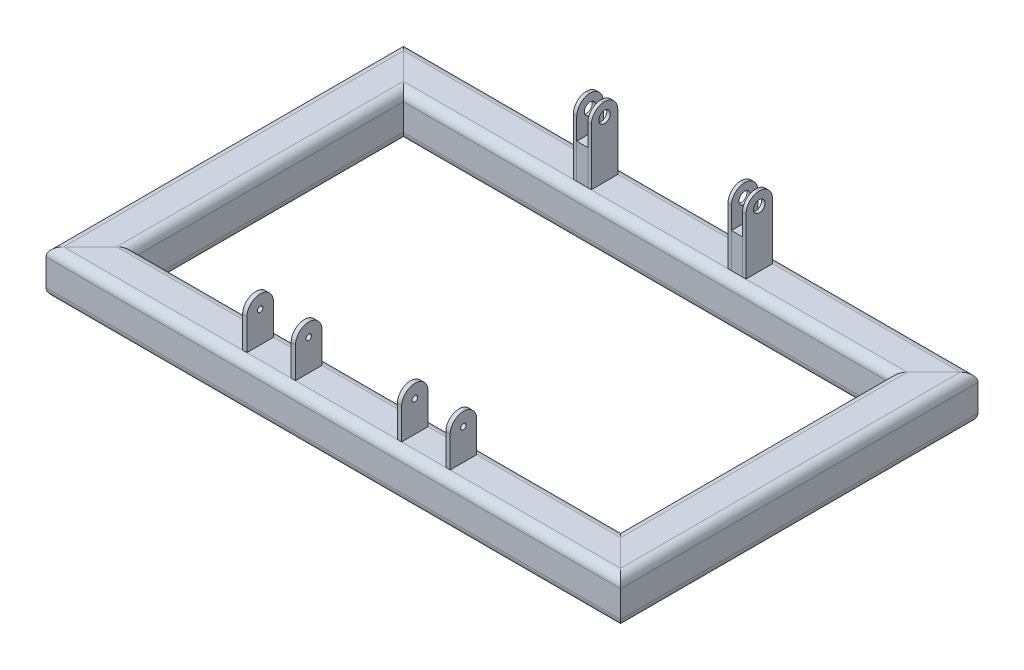
from build123d import *

# Parameters (mm, degrees)
TUBE_SQUARE_TS25X25X2_5_1_DEPTH      = 323.760512242
TUBE_SQUARE_TS25X25X2_5_1_DEPTH_BACK = 18.960512242
TUBE_SQUARE_TS25X25X2_5_1_2_DEPTH    = 217.921024484
TUBE_SQUARE_TS25X25X2_5_1_3_DEPTH    = 342.721024484
TUBE_SQUARE_TS25X25X2_5_1_4_DEPTH    = 217.921024484
SKETCH124_W                          = 2.5
SKETCH124_H                          = 15.24
BOSS_EXTRUDE1_DEPTH                  = 25.4
BOSS_EXTRUDE1_2_DEPTH                = 25.4
SKETCH124_W_2                        = 2.502031313
BOSS_EXTRUDE1_3_DEPTH                = 25.4
BOSS_EXTRUDE1_4_DEPTH                = 25.4
SKETCH125_R                          = 1.5875
CUT_EXTRUDE1_DEPTH                   = 297.651541074
SKETCH126_W                          = 2
SKETCH126_H                          = 15.24
BOSS_EXTRUDE2_DEPTH                  = 40
BOSS_EXTRUDE2_2_DEPTH                = 40
BOSS_EXTRUDE2_3_DEPTH                = 40
BOSS_EXTRUDE2_4_DEPTH                = 40
SKETCH129_R                          = 3.295
CUT_EXTRUDE7_DEPTH                   = 296.090946455
SKETCH130_W                          = 6.35
SKETCH130_H                          = 15.24
BOSS_EXTRUDE3_DEPTH                  = 20
SKETCH130_W_2                        = 6.36
BOSS_EXTRUDE3_2_DEPTH                = 20


with BuildPart() as part:
    # Sketch123 → Tube square TS25X25X2.5(1) (new, two sides)
    with BuildSketch(Plane.ZY.offset(-304.8)) as tube_square_ts25x25x2_5_1_sk:
        with BuildLine():
            Line((-7.62, -12.7), (7.62, -12.7))
            ThreePointArc((7.62, -12.7), (11.212102448, -11.212102448), (12.7, -7.62))
            Line((12.7, -7.62), (12.7, 7.62))
            ThreePointArc((12.7, 7.62), (11.212102448, 11.212102448), (7.62, 12.7))
            Line((7.62, 12.7), (-7.62, 12.7))
            ThreePointArc((-7.62, 12.7), (-11.212102448, 11.212102448), (-12.7, 7.62))
            Line((-12.7, 7.62), (-12.7, -7.62))
            ThreePointArc((-12.7, -7.62), (-11.212102448, -11.212102448), (-7.62, -12.7))
        make_face()
        with BuildLine():
            Line((-7.62, -10.16), (7.62, -10.16))
            ThreePointArc((7.62, -10.16), (9.416051224, -9.416051224), (10.16, -7.62))
            Line((10.16, -7.62), (10.16, 7.62))
            ThreePointArc((10.16, 7.62), (9.416051224, 9.416051224), (7.62, 10.16))
            Line((7.62, 10.16), (-7.62, 10.16))
            ThreePointArc((-7.62, 10.16), (-9.416051224, 9.416051224), (-10.16, 7.62))
            Line((-10.16, 7.62), (-10.16, -7.62))
            ThreePointArc((-10.16, -7.62), (-9.416051224, -9.416051224), (-7.62, -10.16))
        make_face(mode=Mode.SUBTRACT)
    extrude(amount=TUBE_SQUARE_TS25X25X2_5_1_DEPTH)
    extrude(tube_square_ts25x25x2_5_1_sk.sketch, amount=-TUBE_SQUARE_TS25X25X2_5_1_DEPTH_BACK)

    # Tube square TS25X25X2.5(1) mitre 1
    split(bisect_by=Plane(origin=(304.8, 0, 0), x_dir=(0, -1, 0), z_dir=(-0.707106781, 0, 0.707106781)), keep=Keep.TOP)

    # Tube square TS25X25X2.5(1) mitre 2
    split(bisect_by=Plane(origin=(0, 0, 0), x_dir=(0, 1, 0), z_dir=(0.707106781, 0, 0.707106781)), keep=Keep.TOP)


with BuildPart() as body_2:
    # Sketch123 on segment 2 (carried to segment 2) → Tube square TS25X25X2.5_1 2 (new body)
    with BuildSketch(Plane(origin=(0, 0, 18.960512242), x_dir=(-1, 0, 0), z_dir=(0, 0, -1))):
        with BuildLine():
            Line((-7.62, -12.7), (7.62, -12.7))
            ThreePointArc((7.62, -12.7), (11.212102448, -11.212102448), (12.7, -7.62))
            Line((12.7, -7.62), (12.7, 7.62))
            ThreePointArc((12.7, 7.62), (11.212102448, 11.212102448), (7.62, 12.7))
            Line((7.62, 12.7), (-7.62, 12.7))
            ThreePointArc((-7.62, 12.7), (-11.212102448, 11.212102448), (-12.7, 7.62))
            Line((-12.7, 7.62), (-12.7, -7.62))
            ThreePointArc((-12.7, -7.62), (-11.212102448, -11.212102448), (-7.62, -12.7))
        make_face()
        with BuildLine():
            Line((-7.62, -10.16), (7.62, -10.16))
            ThreePointArc((7.62, -10.16), (9.416051224, -9.416051224), (10.16, -7.62))
            Line((10.16, -7.62), (10.16, 7.62))
            ThreePointArc((10.16, 7.62), (9.416051224, 9.416051224), (7.62, 10.16))
            Line((7.62, 10.16), (-7.62, 10.16))
            ThreePointArc((-7.62, 10.16), (-9.416051224, 9.416051224), (-10.16, 7.62))
            Line((-10.16, 7.62), (-10.16, -7.62))
            ThreePointArc((-10.16, -7.62), (-9.416051224, -9.416051224), (-7.62, -10.16))
        make_face(mode=Mode.SUBTRACT)
    extrude(amount=TUBE_SQUARE_TS25X25X2_5_1_2_DEPTH)

    # Tube square TS25X25X2.5_1 2 mitre 1
    split(bisect_by=Plane(origin=(0, 0, 0), x_dir=(0, -1, 0), z_dir=(-0.707106781, 0, -0.707106781)), keep=Keep.TOP)

    # Tube square TS25X25X2.5_1 2 mitre 2
    split(bisect_by=Plane(origin=(0, 0, -180), x_dir=(0, -1, 0), z_dir=(-0.707106781, 0, 0.707106781)), keep=Keep.TOP)


with BuildPart() as body_3:
    # Sketch123 on segment 3 (carried to segment 3) → Tube square TS25X25X2.5_1 3 (new body)
    with BuildSketch(Plane(origin=(-18.960512242, 0, -180), x_dir=(0, 0, -1), z_dir=(1, 0, 0))):
        with BuildLine():
            Line((-7.62, -12.7), (7.62, -12.7))
            ThreePointArc((7.62, -12.7), (11.212102448, -11.212102448), (12.7, -7.62))
            Line((12.7, -7.62), (12.7, 7.62))
            ThreePointArc((12.7, 7.62), (11.212102448, 11.212102448), (7.62, 12.7))
            Line((7.62, 12.7), (-7.62, 12.7))
            ThreePointArc((-7.62, 12.7), (-11.212102448, 11.212102448), (-12.7, 7.62))
            Line((-12.7, 7.62), (-12.7, -7.62))
            ThreePointArc((-12.7, -7.62), (-11.212102448, -11.212102448), (-7.62, -12.7))
        make_face()
        with BuildLine():
            Line((-7.62, -10.16), (7.62, -10.16))
            ThreePointArc((7.62, -10.16), (9.416051224, -9.416051224), (10.16, -7.62))
            Line((10.16, -7.62), (10.16, 7.62))
            ThreePointArc((10.16, 7.62), (9.416051224, 9.416051224), (7.62, 10.16))
            Line((7.62, 10.16), (-7.62, 10.16))
            ThreePointArc((-7.62, 10.16), (-9.416051224, 9.416051224), (-10.16, 7.62))
            Line((-10.16, 7.62), (-10.16, -7.62))
            ThreePointArc((-10.16, -7.62), (-9.416051224, -9.416051224), (-7.62, -10.16))
        make_face(mode=Mode.SUBTRACT)
    extrude(amount=TUBE_SQUARE_TS25X25X2_5_1_3_DEPTH)

    # Tube square TS25X25X2.5_1 3 mitre 1
    split(bisect_by=Plane(origin=(0, 0, -180), x_dir=(0, 1, 0), z_dir=(0.707106781, 0, -0.707106781)), keep=Keep.TOP)

    # Tube square TS25X25X2.5_1 3 mitre 2
    split(bisect_by=Plane(origin=(304.8, 0, -180), x_dir=(0, -1, 0), z_dir=(-0.707106781, 0, -0.707106781)), keep=Keep.TOP)


with BuildPart() as body_4:
    # Sketch123 on segment 4 (carried to segment 4) → Tube square TS25X25X2.5_1 4 (new body)
    with BuildSketch(Plane(origin=(304.8, 0, -198.960512242), x_dir=(1, 0, 0), z_dir=(0, 0, 1))):
        with BuildLine():
            Line((-7.62, -12.7), (7.62, -12.7))
            ThreePointArc((7.62, -12.7), (11.212102448, -11.212102448), (12.7, -7.62))
            Line((12.7, -7.62), (12.7, 7.62))
            ThreePointArc((12.7, 7.62), (11.212102448, 11.212102448), (7.62, 12.7))
            Line((7.62, 12.7), (-7.62, 12.7))
            ThreePointArc((-7.62, 12.7), (-11.212102448, 11.212102448), (-12.7, 7.62))
            Line((-12.7, 7.62), (-12.7, -7.62))
            ThreePointArc((-12.7, -7.62), (-11.212102448, -11.212102448), (-7.62, -12.7))
        make_face()
        with BuildLine():
            Line((-7.62, -10.16), (7.62, -10.16))
            ThreePointArc((7.62, -10.16), (9.416051224, -9.416051224), (10.16, -7.62))
            Line((10.16, -7.62), (10.16, 7.62))
            ThreePointArc((10.16, 7.62), (9.416051224, 9.416051224), (7.62, 10.16))
            Line((7.62, 10.16), (-7.62, 10.16))
            ThreePointArc((-7.62, 10.16), (-9.416051224, 9.416051224), (-10.16, 7.62))
            Line((-10.16, 7.62), (-10.16, -7.62))
            ThreePointArc((-10.16, -7.62), (-9.416051224, -9.416051224), (-7.62, -10.16))
        make_face(mode=Mode.SUBTRACT)
    extrude(amount=TUBE_SQUARE_TS25X25X2_5_1_4_DEPTH)

    # Tube square TS25X25X2.5_1 4 mitre 1
    split(bisect_by=Plane(origin=(304.8, 0, -180), x_dir=(0, 1, 0), z_dir=(0.707106781, 0, 0.707106781)), keep=Keep.TOP)

    # Tube square TS25X25X2.5_1 4 mitre 2
    split(bisect_by=Plane(origin=(304.8, 0, 0), x_dir=(0, 1, 0), z_dir=(0.707106781, 0, -0.707106781)), keep=Keep.TOP)


with BuildPart() as body_5:
    # Sketch124 → Boss-Extrude1 (new body)
    with BuildSketch(Plane(origin=(0, 12.7, 0), x_dir=(1, 0, 0), z_dir=(0, 1, 0))):
        with Locations((185.352150923, 0)):
            Rectangle(SKETCH124_W, SKETCH124_H)
    extrude(amount=BOSS_EXTRUDE1_DEPTH)


with BuildPart() as body_6:
    # Sketch124 → Boss-Extrude1 2 (new body)
    with BuildSketch(Plane(origin=(0, 12.7, 0), x_dir=(1, 0, 0), z_dir=(0, 1, 0))):
        with Locations((124.352150923, 0)):
            Rectangle(SKETCH124_W, SKETCH124_H)
    extrude(amount=BOSS_EXTRUDE1_2_DEPTH)


with BuildPart() as body_7:
    # Sketch124 → Boss-Extrude1 3 (new body)
    with BuildSketch(Plane(origin=(0, 12.7, 0), x_dir=(1, 0, 0), z_dir=(0, 1, 0))):
        with Locations((96.451135267, 0)):
            Rectangle(SKETCH124_W_2, SKETCH124_H)
    extrude(amount=BOSS_EXTRUDE1_3_DEPTH)


with BuildPart() as body_8:
    # Sketch124 → Boss-Extrude1 4 (new body)
    with BuildSketch(Plane(origin=(0, 12.7, 0), x_dir=(1, 0, 0), z_dir=(0, 1, 0))):
        with Locations((213.252150923, 0)):
            Rectangle(SKETCH124_W, SKETCH124_H)
    extrude(amount=BOSS_EXTRUDE1_4_DEPTH)


with BuildPart() as cut_extrude1_tool:
    # Sketch125 → Cut-Extrude1 (new, through all)
    with BuildSketch(Plane.ZY.offset(-95.20011961)):
        with Locations(Location((0, 30.48, 0), (0, 0, 270))):
            Circle(SKETCH125_R)
        with BuildLine():
            Line((-9.491057505, 42.478949405), (18.205619096, 42.109929323))
            Line((18.205619096, 42.109929323), (7.62, 30.48))
            ThreePointArc((7.62, 30.48), (0, 38.1), (-7.62, 30.48))
            Line((-7.62, 30.48), (-9.491057505, 42.478949405))
        make_face()
    extrude(amount=-CUT_EXTRUDE1_DEPTH)


with BuildPart() as body_5_1:
    add(body_5.part)

    # Cut-Extrude1: cut by cut_extrude1_tool
    add(cut_extrude1_tool.part, mode=Mode.SUBTRACT)


with BuildPart() as body_6_1:
    add(body_6.part)

    # Cut-Extrude1: cut by cut_extrude1_tool
    add(cut_extrude1_tool.part, mode=Mode.SUBTRACT)


with BuildPart() as body_7_1:
    add(body_7.part)

    # Cut-Extrude1: cut by cut_extrude1_tool
    add(cut_extrude1_tool.part, mode=Mode.SUBTRACT)


with BuildPart() as body_8_1:
    add(body_8.part)

    # Cut-Extrude1: cut by cut_extrude1_tool
    add(cut_extrude1_tool.part, mode=Mode.SUBTRACT)


with BuildPart() as body_9:
    # Sketch126 → Boss-Extrude2 (new body)
    with BuildSketch(Plane(origin=(0, 12.7, 0), x_dir=(1, 0, 0), z_dir=(0, 1, 0))):
        with Locations((114.577150923, 180)):
            Rectangle(SKETCH126_W, SKETCH126_H)
    extrude(amount=BOSS_EXTRUDE2_DEPTH)


with BuildPart() as body_10:
    # Sketch126 → Boss-Extrude2 2 (new body)
    with BuildSketch(Plane(origin=(0, 12.7, 0), x_dir=(1, 0, 0), z_dir=(0, 1, 0))):
        with Locations((106.227150923, 180)):
            Rectangle(SKETCH126_W, SKETCH126_H)
    extrude(amount=BOSS_EXTRUDE2_2_DEPTH)


with BuildPart() as body_11:
    # Sketch126 → Boss-Extrude2 3 (new body)
    with BuildSketch(Plane(origin=(0, 12.7, 0), x_dir=(1, 0, 0), z_dir=(0, 1, 0))):
        with Locations((203.482150923, 180)):
            Rectangle(SKETCH126_W, SKETCH126_H)
    extrude(amount=BOSS_EXTRUDE2_3_DEPTH)


with BuildPart() as body_12:
    # Sketch126 → Boss-Extrude2 4 (new body)
    with BuildSketch(Plane(origin=(0, 12.7, 0), x_dir=(1, 0, 0), z_dir=(0, 1, 0))):
        with Locations((195.122150923, 180)):
            Rectangle(SKETCH126_W, SKETCH126_H)
    extrude(amount=BOSS_EXTRUDE2_4_DEPTH)


with BuildPart() as cut_extrude7_tool:
    # Sketch129 → Cut-Extrude7 (new, through all)
    with BuildSketch(Plane(origin=(204.482150923, 0, 0), x_dir=(0, 0, -1), z_dir=(1, 0, 0))):
        with Locations(Location((180, 45.095923911, 0), (0, 0, 90))):
            Circle(SKETCH129_R)
        with BuildLine():
            Line((172.38, 45.110127094), (170.036470447, 54.665442744))
            Line((170.036470447, 54.665442744), (189.934840012, 53.925976307))
            Line((189.934840012, 53.925976307), (187.62, 45.110127094))
            ThreePointArc((187.62, 45.110127094), (180, 52.715937148), (172.38, 45.110127094))
        make_face()
    extrude(amount=-CUT_EXTRUDE7_DEPTH)


with BuildPart() as body_9_1:
    add(body_9.part)

    # Cut-Extrude7: cut by cut_extrude7_tool
    add(cut_extrude7_tool.part, mode=Mode.SUBTRACT)


with BuildPart() as body_10_1:
    add(body_10.part)

    # Cut-Extrude7: cut by cut_extrude7_tool
    add(cut_extrude7_tool.part, mode=Mode.SUBTRACT)


with BuildPart() as body_11_1:
    add(body_11.part)

    # Cut-Extrude7: cut by cut_extrude7_tool
    add(cut_extrude7_tool.part, mode=Mode.SUBTRACT)


with BuildPart() as body_12_1:
    add(body_12.part)

    # Cut-Extrude7: cut by cut_extrude7_tool
    add(cut_extrude7_tool.part, mode=Mode.SUBTRACT)


with BuildPart() as body_13:
    # Sketch130 → Boss-Extrude3 (new body)
    with BuildSketch(Plane(origin=(0, 12.7, 0), x_dir=(1, 0, 0), z_dir=(0, 1, 0))):
        with Locations((110.402150923, 180)):
            Rectangle(SKETCH130_W, SKETCH130_H)
    extrude(amount=BOSS_EXTRUDE3_DEPTH)


with BuildPart() as body_14:
    # Sketch130 → Boss-Extrude3 2 (new body)
    with BuildSketch(Plane(origin=(0, 12.7, 0), x_dir=(1, 0, 0), z_dir=(0, 1, 0))):
        with Locations((199.302150923, 180)):
            Rectangle(SKETCH130_W_2, SKETCH130_H)
    extrude(amount=BOSS_EXTRUDE3_2_DEPTH)


solid = Compound([part.part, body_2.part, body_3.part, body_4.part, body_5_1.part, body_6_1.part, body_7_1.part, body_8_1.part, body_9_1.part, body_10_1.part, body_11_1.part, body_12_1.part, body_13.part, body_14.part])
